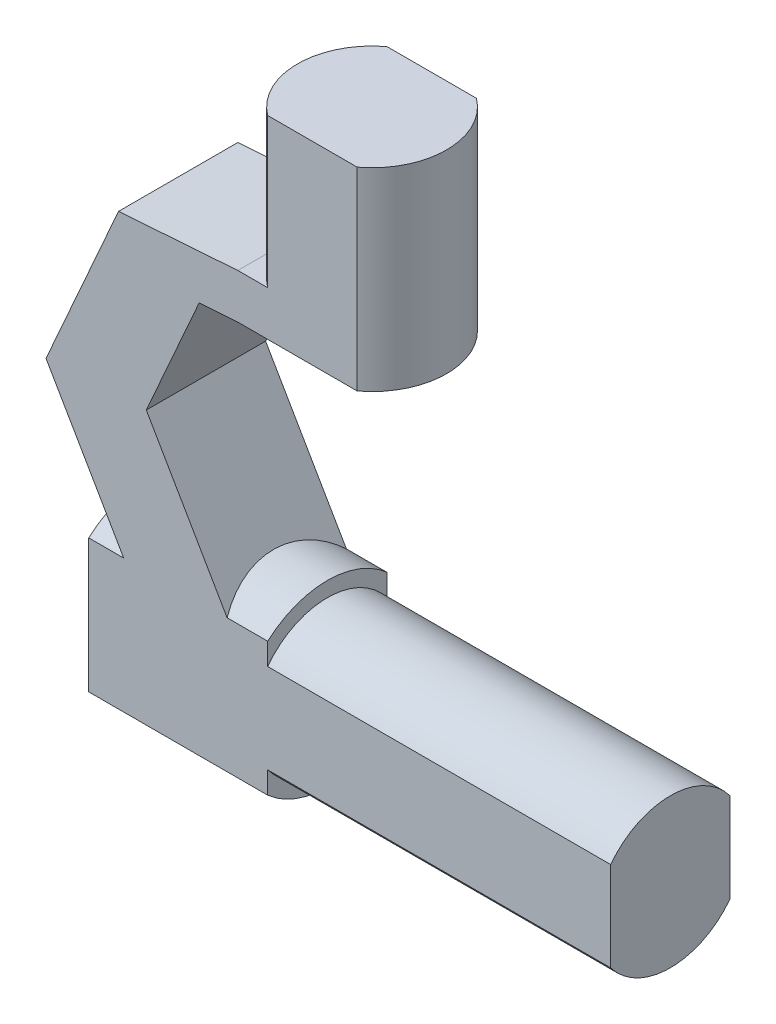
from build123d import *

# Parameters (mm, degrees)
CROQUIS1_R              = 5
SALIENTE_EXTRUIR1_DEPTH = 3
SALIENTE_EXTRUIR2_DEPTH = 4
CROQUIS4_R              = 5
SALIENTE_EXTRUIR3_DEPTH = 15
CROQUIS6_R              = 5
SALIENTE_EXTRUIR5_DEPTH = 20
CROQUIS3_R              = 5
SALIENTE_EXTRUIR7_DEPTH = 10
CROQUIS12_R             = 6
SALIENTE_EXTRUIR8_DEPTH = 12
CROQUIS11_W             = 60
CROQUIS11_H             = 5
CORTAR_EXTRUIR4_DEPTH   = 42


with BuildPart() as part:
    # Croquis1 → Saliente-Extruir1 (new body)
    with BuildSketch(Plane(origin=(0, 0, 0), x_dir=(1, 0, 0), z_dir=(0, 1, 0))):
        Circle(CROQUIS1_R)
    extrude(amount=SALIENTE_EXTRUIR1_DEPTH)

    # Croquis2 → Saliente-Extruir2 (add, symmetric)
    with BuildSketch(Plane.XY):
        Polygon((-5, 3), (-13, 2.43295135), (-17.863199041, -8.537431282), (-8.325792195, -25), (-1.391615301, -25), (-11.139227196, -8.174595228), (-7.597010616, -0.184078921), (-5, 0), (0, 0), (0, 3), align=None)
    extrude(amount=SALIENTE_EXTRUIR2_DEPTH, both=True)

    # Croquis4 → Saliente-Extruir3 (add)
    with BuildSketch(Plane(origin=(0, 0, 0), x_dir=(0, 0, -1), z_dir=(1, 0, 0))):
        with Locations((0, -22)):
            Circle(CROQUIS4_R)
    extrude(amount=-SALIENTE_EXTRUIR3_DEPTH)

    # Croquis6 → Saliente-Extruir5 (add)
    with BuildSketch(Plane(origin=(0, 0, 0), x_dir=(0, 0, -1), z_dir=(1, 0, 0))):
        with Locations((0, -22)):
            Circle(CROQUIS6_R)
    extrude(amount=SALIENTE_EXTRUIR5_DEPTH)

    # Croquis3 → Saliente-Extruir7 (add)
    with BuildSketch(Plane(origin=(0, 3, 0), x_dir=(1, 0, 0), z_dir=(0, 1, 0))):
        Circle(CROQUIS3_R)
    extrude(amount=SALIENTE_EXTRUIR7_DEPTH)

    # Croquis12 → Saliente-Extruir8 (add)
    with BuildSketch(Plane.ZY.offset(15)):
        with Locations((0, -22)):
            Circle(CROQUIS12_R)
    extrude(amount=-SALIENTE_EXTRUIR8_DEPTH)

    # Croquis11 → Cortar-Extruir4 (cut, through all)
    with BuildSketch(Plane(origin=(0, 13, 0), x_dir=(1, 0, 0), z_dir=(0, 1, 0))):
        with Locations((-3, 6.5)):
            Rectangle(CROQUIS11_W, CROQUIS11_H)
        with Locations((-3, -6.5)):
            Rectangle(CROQUIS11_W, CROQUIS11_H)
    extrude(amount=-CORTAR_EXTRUIR4_DEPTH, mode=Mode.SUBTRACT)


solid = part.part
